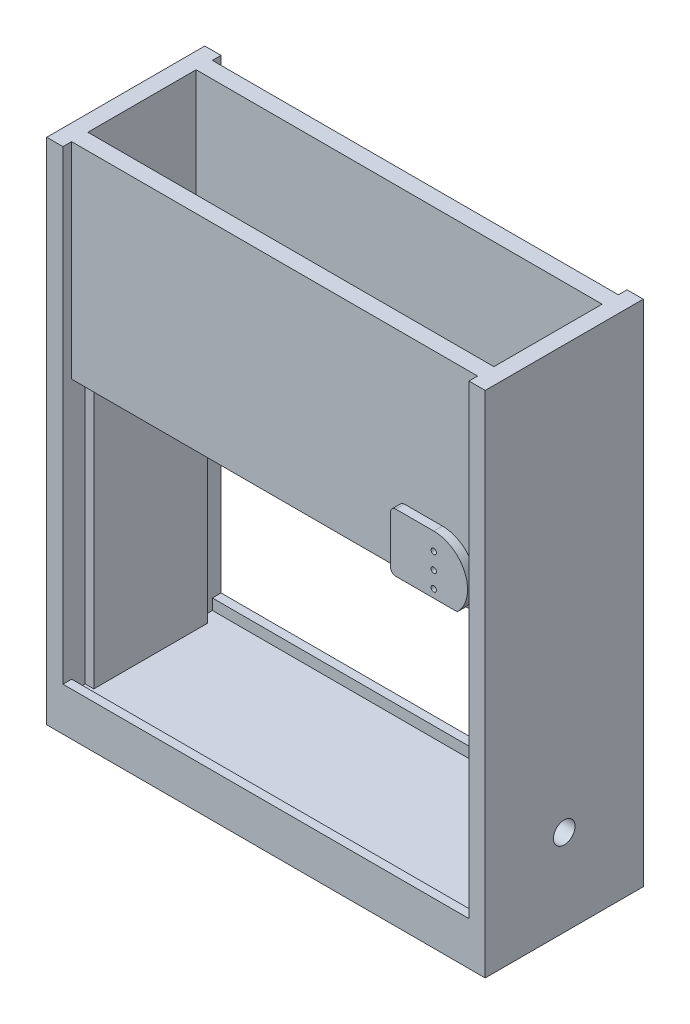
from build123d import *

# Parameters (mm, degrees)
SKETCH1_W            = 150
SKETCH1_H            = 42
BOSS_EXTRUDE1_DEPTH  = 3.2
SKETCH2_W            = 162
SKETCH2_H            = 52
BOSS_EXTRUDE2_DEPTH  = 6
SKETCH3_W            = 6
SKETCH3_H            = 52
BOSS_EXTRUDE3_DEPTH  = 176
BOSS_EXTRUDE4_REACH  = 238.618
SKETCH5_W            = 52
SKETCH5_H            = 6
BOSS_EXTRUDE5_START  = 100
SKETCH1_2_W          = 150
SKETCH1_2_H          = 42
BOSS_EXTRUDE5_DEPTH  = 3.2
SKETCH6_W            = 150
SKETCH6_H            = 6
BOSS_EXTRUDE6_DEPTH  = 70
CUT_EXTRUDE1_REACH   = 142.645
SKETCH7_W            = 10
SKETCH7_H            = 40
SKETCH7_R            = 3
SKETCH7_3_W          = 6
SKETCH7_3_H          = 40
BOSS_EXTRUDE7_DEPTH  = 54
SKETCH8_W            = 162
SKETCH8_H            = 10
BOSS_EXTRUDE8_DEPTH  = 3.2
SKETCH9_W            = 150
SKETCH9_H            = 42
CUT_EXTRUDE2_DEPTH   = 3.2
CUT_EXTRUDE3_DEPTH   = 3.2
BOSS_EXTRUDE9_DEPTH  = 3.2
SKETCH12_W           = 3.2
SKETCH12_H           = 10
BOSS_EXTRUDE10_DEPTH = 6
CUT_EXTRUDE4_REACH   = 236.897
SKETCH13_R           = 4
CUT_EXTRUDE5_REACH   = 201.894
SKETCH14_R           = 1
SKETCH16_W           = 6
SKETCH16_H           = 172
BOSS_EXTRUDE11_DEPTH = 3.2
SKETCH17_W           = 162
SKETCH17_H           = 58.4
SKETCH17_W_2         = 150
SKETCH17_H_2         = 52
BOSS_EXTRUDE12_DEPTH = 6
SKETCH15_R           = 1
BOSS_EXTRUDE14_DEPTH = 3.2
FILLET1_R            = 2
FILLET1_OF_MIRROR4_R = 2


with BuildPart() as part:
    # Sketch1 → Boss-Extrude1 (new body)
    with BuildSketch(Plane(origin=(0, 0, 0), x_dir=(1, 0, 0), z_dir=(0, 1, 0))):
        Rectangle(SKETCH1_W, SKETCH1_H)
    extrude(amount=BOSS_EXTRUDE1_DEPTH)

    # Sketch2 → Boss-Extrude2 (add)
    with BuildSketch(Plane.XZ):
        Rectangle(SKETCH2_W, SKETCH2_H)
    extrude(amount=BOSS_EXTRUDE2_DEPTH)

    # Sketch3 → Boss-Extrude3 (add)
    with BuildSketch(Plane(origin=(0, 0, 0), x_dir=(1, 0, 0), z_dir=(0, 1, 0))):
        with Locations((78, 0)):
            Rectangle(SKETCH3_W, SKETCH3_H)
        with Locations((-78, 0)):
            Rectangle(SKETCH3_W, SKETCH3_H)
    extrude(amount=BOSS_EXTRUDE3_DEPTH)

    # Sketch5 → Boss-Extrude4 (add, up to next)
    with BuildSketch(Plane.ZY.offset(-75), mode=Mode.PRIVATE) as boss_extrude4_sk1:
        with Locations((0, 103)):
            Rectangle(SKETCH5_W, SKETCH5_H)
    boss_extrude4_tool1 = extrude(boss_extrude4_sk1.sketch, amount=BOSS_EXTRUDE4_REACH, mode=Mode.PRIVATE) - part.part
    add(boss_extrude4_tool1.solids().sort_by_distance((75, 103, 0))[0])

    # Sketch1_2 → Boss-Extrude5 (add)
    with BuildSketch(Plane(origin=(0, 0, 0), x_dir=(1, 0, 0), z_dir=(0, 1, 0)).offset(BOSS_EXTRUDE5_START)):
        Rectangle(SKETCH1_2_W, SKETCH1_2_H)
    extrude(amount=-BOSS_EXTRUDE5_DEPTH)

    # Sketch6 → Boss-Extrude6 (add)
    with BuildSketch(Plane(origin=(0, 106, 0), x_dir=(1, 0, 0), z_dir=(0, 1, 0))):
        with Locations((0, -23)):
            Rectangle(SKETCH6_W, SKETCH6_H)
        with Locations((0, 23)):
            Rectangle(SKETCH6_W, SKETCH6_H)
    extrude(amount=BOSS_EXTRUDE6_DEPTH)

    # Sketch7 → Cut-Extrude1 (cut, up to next)
    with BuildSketch(Plane(origin=(0, 106, 0), x_dir=(1, 0, 0), z_dir=(0, 1, 0)), mode=Mode.PRIVATE) as cut_extrude1_sk1:
        with Locations((70, 0)):
            Rectangle(SKETCH7_W, SKETCH7_H)
        with Locations((70, -15)):
            Circle(SKETCH7_R, mode=Mode.SUBTRACT)
        with Locations((70, 15)):
            Circle(SKETCH7_R, mode=Mode.SUBTRACT)
    cut_extrude1_tool1 = extrude(cut_extrude1_sk1.sketch, amount=-CUT_EXTRUDE1_REACH, mode=Mode.PRIVATE) & part.part
    # Sketch7 → Cut-Extrude1 (cut, up to next)
    with BuildSketch(Plane(origin=(0, 106, 0), x_dir=(1, 0, 0), z_dir=(0, 1, 0)), mode=Mode.PRIVATE) as cut_extrude1_sk2:
        with Locations((70, -15)):
            Circle(SKETCH7_R)
    cut_extrude1_tool2 = extrude(cut_extrude1_sk2.sketch, amount=-CUT_EXTRUDE1_REACH, mode=Mode.PRIVATE) & part.part
    # Sketch7 → Cut-Extrude1 (cut, up to next)
    with BuildSketch(Plane(origin=(0, 106, 0), x_dir=(1, 0, 0), z_dir=(0, 1, 0)), mode=Mode.PRIVATE) as cut_extrude1_sk3:
        with Locations((70, 15)):
            Circle(SKETCH7_R)
    cut_extrude1_tool3 = extrude(cut_extrude1_sk3.sketch, amount=-CUT_EXTRUDE1_REACH, mode=Mode.PRIVATE) & part.part
    add(cut_extrude1_tool1.solids().sort_by_distance((70, 106, 0))[0], mode=Mode.SUBTRACT)
    add(cut_extrude1_tool2.solids().sort_by_distance((70, 106, 15))[0], mode=Mode.SUBTRACT)
    add(cut_extrude1_tool3.solids().sort_by_distance((70, 106, -15))[0], mode=Mode.SUBTRACT)

    # Sketch7_3 → Boss-Extrude7 (add)
    with BuildSketch(Plane(origin=(0, 106, 0), x_dir=(1, 0, 0), z_dir=(0, 1, 0))):
        with Locations((62, 0)):
            Rectangle(SKETCH7_3_W, SKETCH7_3_H)
    extrude(amount=BOSS_EXTRUDE7_DEPTH)

    # Sketch8 → Boss-Extrude8 (add)
    with BuildSketch(Plane(origin=(0, 0, -26), x_dir=(-1, 0, 0), z_dir=(0, 0, -1))):
        with Locations((0, -1)):
            Rectangle(SKETCH8_W, SKETCH8_H)
    boss_extrude8 = extrude(amount=BOSS_EXTRUDE8_DEPTH)

    # Mirror1: Boss-Extrude8 across plane
    add(boss_extrude8.mirror(Plane.XY))

    # Sketch9 → Cut-Extrude2 (cut)
    with BuildSketch(Plane(origin=(0, 3.2, 0), x_dir=(1, 0, 0), z_dir=(0, 1, 0))):
        Rectangle(SKETCH9_W, SKETCH9_H)
    extrude(amount=-CUT_EXTRUDE2_DEPTH, mode=Mode.SUBTRACT)

    # Sketch10 → Cut-Extrude3 (cut)
    with BuildSketch(Plane.XZ.offset(-96.8)):
        Polygon((-75, -21), (75, -21), (75, -20), (65, -20), (65, 20), (75, 20), (75, 21), (-75, 21), align=None)
    extrude(amount=-CUT_EXTRUDE3_DEPTH, mode=Mode.SUBTRACT)

    # Sketch11 → Boss-Extrude9 (add)
    with BuildSketch(Plane.ZY.offset(-75)):
        Polygon((10, 93.5), (-21, 93.5), (-21, 0), (21, 0), (21, 100), (10, 100), align=None)
    boss_extrude9 = extrude(amount=BOSS_EXTRUDE9_DEPTH)

    # Mirror2: Boss-Extrude9 across plane
    add(boss_extrude9.mirror(Plane(origin=(0, 0, 0), x_dir=(0, 0, 1), z_dir=(1, 0, 0))))

    # Sketch12 → Boss-Extrude10 (add)
    with BuildSketch(Plane(origin=(0, 100, 0), x_dir=(1, 0, 0), z_dir=(0, 1, 0))):
        with Locations((73.4, -15)):
            Rectangle(SKETCH12_W, SKETCH12_H)
    extrude(amount=BOSS_EXTRUDE10_DEPTH)

    # Sketch13 → Cut-Extrude4 (cut, up to next)
    with BuildSketch(Plane.ZY.offset(-71.8), mode=Mode.PRIVATE) as cut_extrude4_sk1:
        with Locations((0, 20)):
            Circle(SKETCH13_R)
    cut_extrude4_tool1 = extrude(cut_extrude4_sk1.sketch, amount=-CUT_EXTRUDE4_REACH, mode=Mode.PRIVATE) & part.part
    add(cut_extrude4_tool1.solids().sort_by_distance((71.8, 20, 0))[0], mode=Mode.SUBTRACT)

    # Sketch14 → Cut-Extrude5 (cut, up to next)
    with BuildSketch(Plane.XY.offset(-20), mode=Mode.PRIVATE) as cut_extrude5_sk1:
        with Locations((62, 103)):
            Circle(SKETCH14_R)
    cut_extrude5_tool1 = extrude(cut_extrude5_sk1.sketch, amount=-CUT_EXTRUDE5_REACH, mode=Mode.PRIVATE) & part.part
    # Sketch14 → Cut-Extrude5 (cut, up to next)
    with BuildSketch(Plane.XY.offset(-20), mode=Mode.PRIVATE) as cut_extrude5_sk2:
        with Locations((62, 109)):
            Circle(SKETCH14_R)
    cut_extrude5_tool2 = extrude(cut_extrude5_sk2.sketch, amount=-CUT_EXTRUDE5_REACH, mode=Mode.PRIVATE) & part.part
    # Sketch14 → Cut-Extrude5 (cut, up to next)
    with BuildSketch(Plane.XY.offset(-20), mode=Mode.PRIVATE) as cut_extrude5_sk3:
        with Locations((62, 115)):
            Circle(SKETCH14_R)
    cut_extrude5_tool3 = extrude(cut_extrude5_sk3.sketch, amount=-CUT_EXTRUDE5_REACH, mode=Mode.PRIVATE) & part.part
    add(cut_extrude5_tool1.solids().sort_by_distance((62, 103, -20))[0], mode=Mode.SUBTRACT)
    add(cut_extrude5_tool2.solids().sort_by_distance((62, 109, -20))[0], mode=Mode.SUBTRACT)
    add(cut_extrude5_tool3.solids().sort_by_distance((62, 115, -20))[0], mode=Mode.SUBTRACT)

    # Sketch16 → Boss-Extrude11 (add)
    with BuildSketch(Plane(origin=(0, 0, -26), x_dir=(-1, 0, 0), z_dir=(0, 0, -1))):
        with Locations((78, 90)):
            Rectangle(SKETCH16_W, SKETCH16_H)
        with Locations((-78, 90)):
            Rectangle(SKETCH16_W, SKETCH16_H)
    boss_extrude11 = extrude(amount=BOSS_EXTRUDE11_DEPTH)

    # Mirror3: Boss-Extrude11 across plane
    add(boss_extrude11.mirror(Plane.XY))

    # Sketch17 → Boss-Extrude12 (add)
    with BuildSketch(Plane.XZ.offset(6)):
        Rectangle(SKETCH17_W, SKETCH17_H)
        Rectangle(SKETCH17_W_2, SKETCH17_H_2, mode=Mode.SUBTRACT)
    extrude(amount=BOSS_EXTRUDE12_DEPTH)

    # Sketch15 → Boss-Extrude14 (add)
    with BuildSketch(Plane(origin=(0, 0, -26), x_dir=(-1, 0, 0), z_dir=(0, 0, -1))):
        with BuildLine():
            ThreePointArc((-62, 121.5), (-50.407976881, 113.677071733), (-53.325324214, 100))
            Line((-53.325324214, 100), (-46, 100))
            Line((-46, 100), (-46, 121.5))
            Line((-46, 121.5), (-62, 121.5))
        make_face()
        with BuildLine():
            ThreePointArc((-62, 121.5), (-73.592023119, 113.677071733), (-70.674675786, 100))
            Line((-70.674675786, 100), (-53.325324214, 100))
            ThreePointArc((-53.325324214, 100), (-50.407976881, 113.677071733), (-62, 121.5))
        make_face()
        with Locations(Location((-62, 103, 0), (0, 0, 180))):
            Circle(SKETCH15_R, mode=Mode.SUBTRACT)
        with Locations(Location((-62, 109, 0), (0, 0, 180))):
            Circle(SKETCH15_R, mode=Mode.SUBTRACT)
        with Locations(Location((-62, 115, 0), (0, 0, 180))):
            Circle(SKETCH15_R, mode=Mode.SUBTRACT)
    boss_extrude14 = extrude(amount=BOSS_EXTRUDE14_DEPTH)

    # Fillet1
    fillet1_edges = [part.edges().sort_by_distance(p)[0] for p in [
        (46, 121.5, -27.6),
        (46, 100, -27.6),
    ]]
    fillet(fillet1_edges, radius=FILLET1_R)

    # Mirror4: Boss-Extrude14 across plane
    add(boss_extrude14.mirror(Plane.XY))

    # Fillet1 of Mirror4
    fillet1_of_mirror4_edges = [part.edges().sort_by_distance(p)[0] for p in [
        (46, 121.5, 27.6),
        (46, 100, 27.6),
    ]]
    fillet(fillet1_of_mirror4_edges, radius=FILLET1_OF_MIRROR4_R)


solid = part.part
